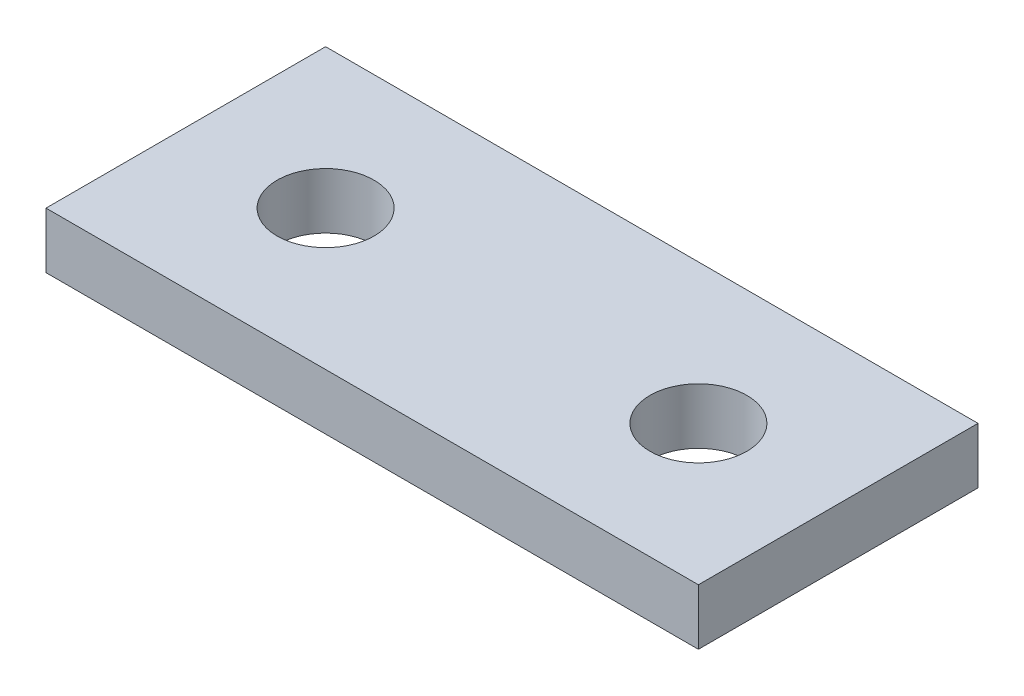
from build123d import *

# Parameters (mm, degrees)
SKETCH_1_W      = 35
SKETCH_1_H      = 15
SKETCH_1_R      = 2.6
EXTRUDE_1_DEPTH = 3


with BuildPart() as part:
    # Эскиз1 → Бобышка-Вытянуть1 (new body)
    with BuildSketch(Plane(origin=(0, 0, 0), x_dir=(1, 0, 0), z_dir=(0, 1, 0))):
        Rectangle(SKETCH_1_W, SKETCH_1_H)
        with Locations((10, 0)):
            Circle(SKETCH_1_R, mode=Mode.SUBTRACT)
        with Locations((-10, 0)):
            Circle(SKETCH_1_R, mode=Mode.SUBTRACT)
    extrude(amount=EXTRUDE_1_DEPTH)


solid = part.part
